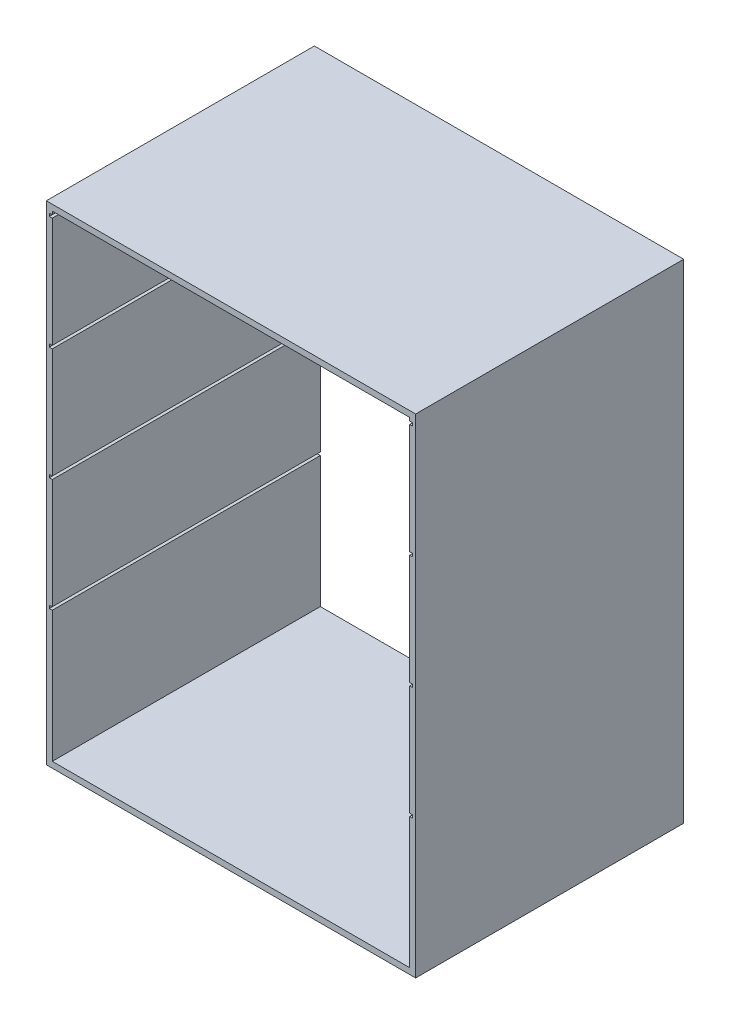
from build123d import *

# Parameters (mm, degrees)
SKETCH1_W               = 620
SKETCH1_H               = 820
SKETCH1_W_2             = 600
SKETCH1_H_2             = 800
EXTRUDE_THIN1_DEPTH     = 450
SKETCH2_W               = 610
SKETCH2_H               = 5
CUT_EXTRUDE1_DEPTH      = 1000
CUT_EXTRUDE1_DEPTH_BACK = 1000
SKETCH3_R               = 10
CUT_EXTRUDE2_DEPTH      = 3


with BuildPart() as part:
    # Sketch1 → Extrude-Thin1 (new body)
    with BuildSketch(Plane.XY):
        with Locations((300, 400)):
            Rectangle(SKETCH1_W, SKETCH1_H)
        with Locations((300, 400)):
            Rectangle(SKETCH1_W_2, SKETCH1_H_2, mode=Mode.SUBTRACT)
    extrude(amount=EXTRUDE_THIN1_DEPTH)

    # Sketch2 → Cut-Extrude1 (cut, two sides)
    with BuildSketch(Plane.XY) as cut_extrude1_sk:
        with Locations((300, 602.200684115)):
            Rectangle(SKETCH2_W, SKETCH2_H)
        with Locations((300, 792.200684115)):
            Rectangle(SKETCH2_W, SKETCH2_H)
        with Locations((300, 412.200684115)):
            Rectangle(SKETCH2_W, SKETCH2_H)
        with Locations((300, 222.200684115)):
            Rectangle(SKETCH2_W, SKETCH2_H)
    extrude(amount=CUT_EXTRUDE1_DEPTH, mode=Mode.SUBTRACT)
    extrude(cut_extrude1_sk.sketch, amount=-CUT_EXTRUDE1_DEPTH_BACK, mode=Mode.SUBTRACT)

    # Sketch3 → Cut-Extrude2 (cut)
    with BuildSketch(Plane(origin=(0, -10, 0), x_dir=(-1, 0, 0), z_dir=(0, -1, 0))):
        with Locations((-560, -50)):
            Circle(SKETCH3_R)
        with Locations((-40, -50)):
            Circle(SKETCH3_R)
        with Locations((-560, -400)):
            Circle(SKETCH3_R)
        with Locations((-40, -400)):
            Circle(SKETCH3_R)
    extrude(amount=-CUT_EXTRUDE2_DEPTH, mode=Mode.SUBTRACT)


solid = part.part
